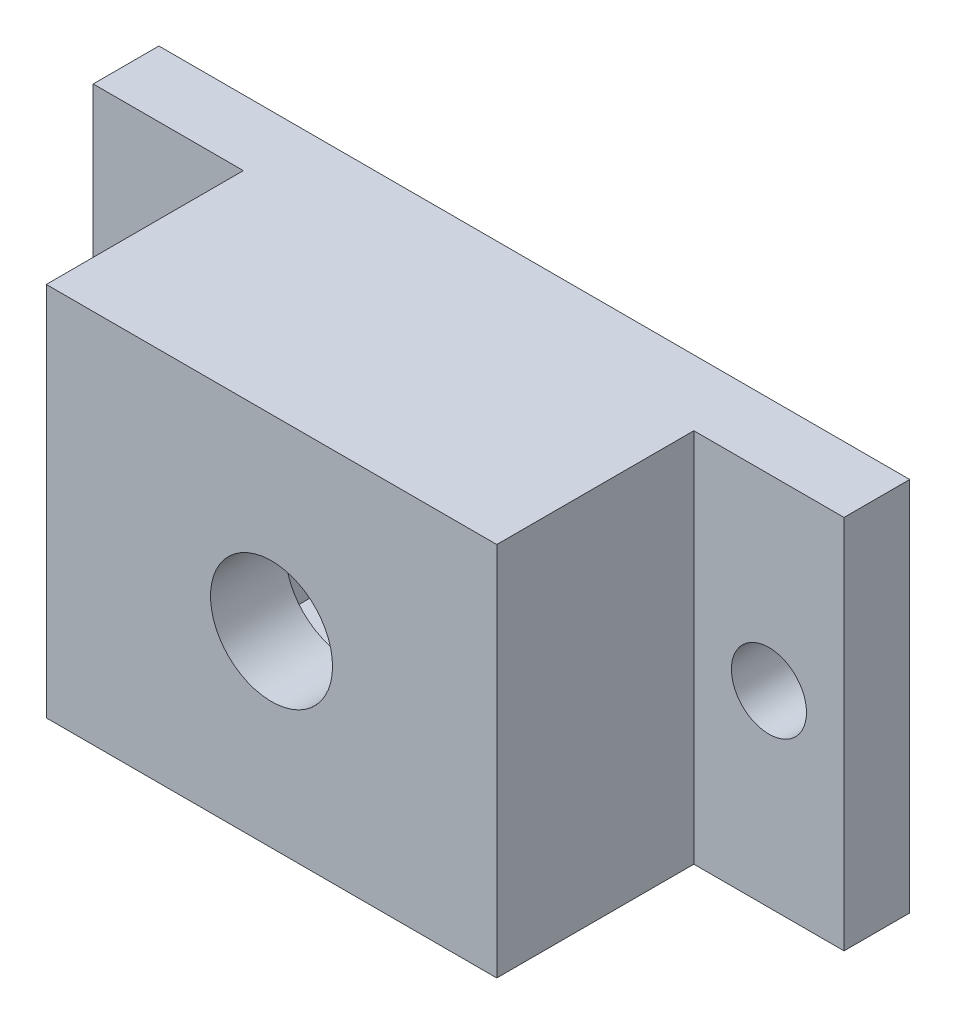
from build123d import *

# Parameters (mm, degrees)
SKETCH2_W           = 40
SKETCH2_H           = 20
SKETCH2_R           = 2
BOSS_EXTRUDE1_DEPTH = 3.5
SKETCH3_W           = 24
SKETCH3_H           = 20
BOSS_EXTRUDE2_DEPTH = 10.5
SKETCH4_W           = 18
SKETCH4_H           = 17
CUT_EXTRUDE2_DEPTH  = 10
SKETCH5_R           = 3.25
CUT_EXTRUDE3_DEPTH  = 15


with BuildPart() as part:
    # Sketch2 → Boss-Extrude1 (new body)
    with BuildSketch(Plane.XY):
        with Locations((-41.200062639, 6.409268178)):
            Rectangle(SKETCH2_W, SKETCH2_H)
        with Locations((-57.200062639, 6.409268178)):
            Circle(SKETCH2_R, mode=Mode.SUBTRACT)
        with Locations((-25.200062639, 6.409268178)):
            Circle(SKETCH2_R, mode=Mode.SUBTRACT)
    extrude(amount=BOSS_EXTRUDE1_DEPTH)

    # Sketch3 → Boss-Extrude2 (add)
    with BuildSketch(Plane.XY.offset(3.5)):
        with Locations((-41.200062639, 6.409268178)):
            Rectangle(SKETCH3_W, SKETCH3_H)
    extrude(amount=BOSS_EXTRUDE2_DEPTH)

    # Sketch4 → Cut-Extrude2 (cut)
    with BuildSketch(Plane(origin=(0, 0, 0), x_dir=(-1, 0, 0), z_dir=(0, 0, -1))):
        with Locations((41.200062639, 6.409268178)):
            Rectangle(SKETCH4_W, SKETCH4_H)
    extrude(amount=-CUT_EXTRUDE2_DEPTH, mode=Mode.SUBTRACT)

    # Sketch5 → Cut-Extrude3 (cut, through all)
    with BuildSketch(Plane.XY.offset(14)):
        with Locations((-41.200062639, 6.409268178)):
            Circle(SKETCH5_R)
    extrude(amount=-CUT_EXTRUDE3_DEPTH, mode=Mode.SUBTRACT)


solid = part.part
